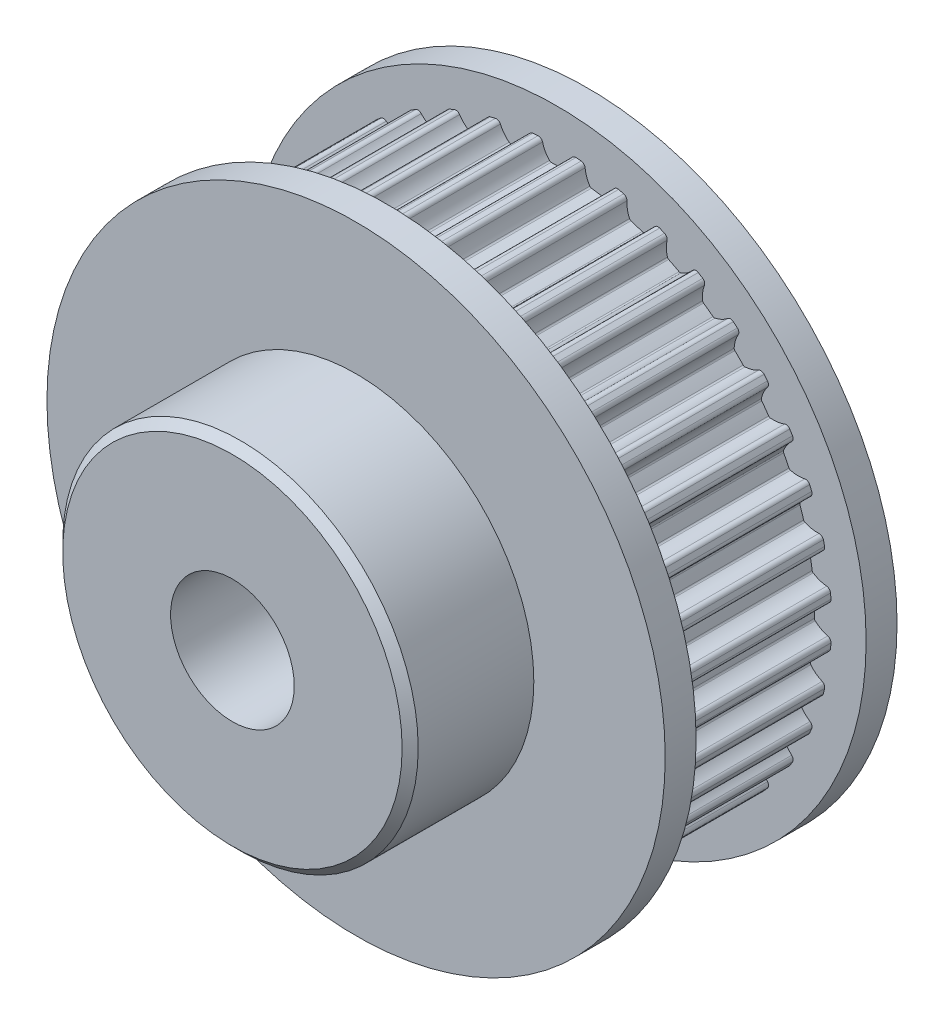
from build123d import *

# Parameters (mm, degrees)
SKETCH_1_R               = 17.765
EXTRUDE_1_DEPTH          = 5.5
CUT_EXTRUDE_START        = -12
CUT_EXTRUDE_1_DEPTH      = 13
PATTERN_CIRCULAR_1_COUNT = 40
SKETCH_3_R               = 20
EXTRUDE_2_DEPTH          = 2
SKETCH_9_R               = 20
EXTRUDE_3_DEPTH          = 2
SKETCH1_R                = 11.5
BOSS_EXTRUDE1_DEPTH      = 8
SKETCH_4_R               = 4
CUT_EXTRUDE_2_DEPTH      = 9
CUT_EXTRUDE_2_DEPTH_BACK = 16
CHAMFER1_SIZE            = 0.52


with BuildPart() as part:
    # 草圖1 → 填料-伸長1 (new body, symmetric)
    with BuildSketch(Plane.XY):
        Circle(SKETCH_1_R)
    extrude(amount=EXTRUDE_1_DEPTH, both=True)

    # 草圖2 → 除料-伸長1 (cut)
    with BuildSketch(Plane.XY.offset(5.5).offset(CUT_EXTRUDE_START)):
        with BuildLine():
            ThreePointArc((-0.380313398, 16.650657246), (0, 16.655), (0.380313398, 16.650657246))
            ThreePointArc((0.380313398, 16.650657246), (0.44332155, 16.662959592), (0.495415763, 16.700477158))
            ThreePointArc((0.495415763, 16.700477158), (0.763361527, 17.081597098), (0.934577473, 17.514878115))
            ThreePointArc((0.934577473, 17.514878115), (1.042191202, 17.670992256), (1.224603763, 17.722741623))
            ThreePointArc((1.224603763, 17.722741623), (0, 17.765), (-1.224603763, 17.722741623))
            ThreePointArc((-1.224603763, 17.722741623), (-1.042191202, 17.670992256), (-0.934577473, 17.514878115))
            ThreePointArc((-0.934577473, 17.514878115), (-0.763361527, 17.081597098), (-0.495415763, 16.700477158))
            ThreePointArc((-0.495415763, 16.700477158), (-0.44332155, 16.662959592), (-0.380313398, 16.650657246))
        make_face()
    cut_extrude_1 = extrude(amount=CUT_EXTRUDE_1_DEPTH, mode=Mode.SUBTRACT)

    # 環狀複製排列1: 除料-伸長1 ×40 about axis
    pattern_circular_1_axis = Axis((0, 0, 0), (0, 0, 1))
    for i in range(1, PATTERN_CIRCULAR_1_COUNT):
        add(cut_extrude_1.rotate(pattern_circular_1_axis, i * 360 / PATTERN_CIRCULAR_1_COUNT), mode=Mode.SUBTRACT)

    # 草圖3 → 填料-伸長2 (add)
    with BuildSketch(Plane.XY.offset(5.5)):
        Circle(SKETCH_3_R)
    extrude(amount=EXTRUDE_2_DEPTH)

    # 草圖9 → 填料-伸長3 (add)
    with BuildSketch(Plane(origin=(0, 0, -5.5), x_dir=(-1, 0, 0), z_dir=(0, 0, -1))):
        Circle(SKETCH_9_R)
    extrude(amount=EXTRUDE_3_DEPTH)

    # Sketch1 → Boss-Extrude1 (add)
    with BuildSketch(Plane.XY.offset(7.5)):
        Circle(SKETCH1_R)
    extrude(amount=BOSS_EXTRUDE1_DEPTH)

    # 草圖4 → 除料-伸長2 (cut, two sides)
    with BuildSketch(Plane.XY.offset(7.5)) as cut_extrude_2_sk:
        Circle(SKETCH_4_R)
    extrude(amount=CUT_EXTRUDE_2_DEPTH, mode=Mode.SUBTRACT)
    extrude(cut_extrude_2_sk.sketch, amount=-CUT_EXTRUDE_2_DEPTH_BACK, mode=Mode.SUBTRACT)

    # Chamfer1
    chamfer1_edges = [part.edges().sort_by_distance(p)[0] for p in [
        (-11.5, 0, 15.5),
    ]]
    chamfer(chamfer1_edges, length=CHAMFER1_SIZE)


solid = part.part
